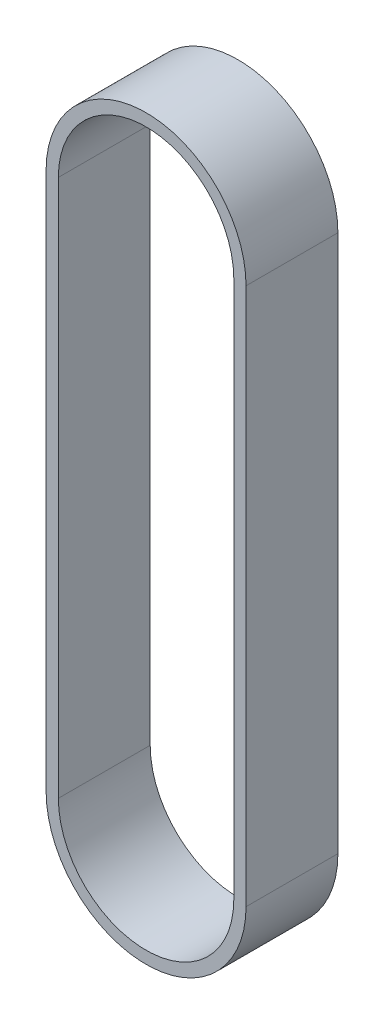
from build123d import *

# Parameters (mm, degrees)
EXTRUDE_1_DEPTH = 7.5


with BuildPart() as part:
    # 草图1 → 拉伸-薄壁1 (new body, symmetric)
    with BuildSketch(Plane.XY):
        with BuildLine():
            Line((-16.325, -87.8), (-16.325, 0))
            ThreePointArc((-16.325, 0), (0, 16.325), (16.325, 0))
            Line((16.325, 0), (16.325, -87.8))
            ThreePointArc((16.325, -87.8), (0, -104.125), (-16.325, -87.8))
        make_face()
        with BuildLine():
            Line((-14.325, -87.8), (-14.325, 0))
            ThreePointArc((-14.325, 0), (0, 14.325), (14.325, 0))
            Line((14.325, 0), (14.325, -87.8))
            ThreePointArc((14.325, -87.8), (0, -102.125), (-14.325, -87.8))
        make_face(mode=Mode.SUBTRACT)
    extrude(amount=EXTRUDE_1_DEPTH, both=True)


solid = part.part
